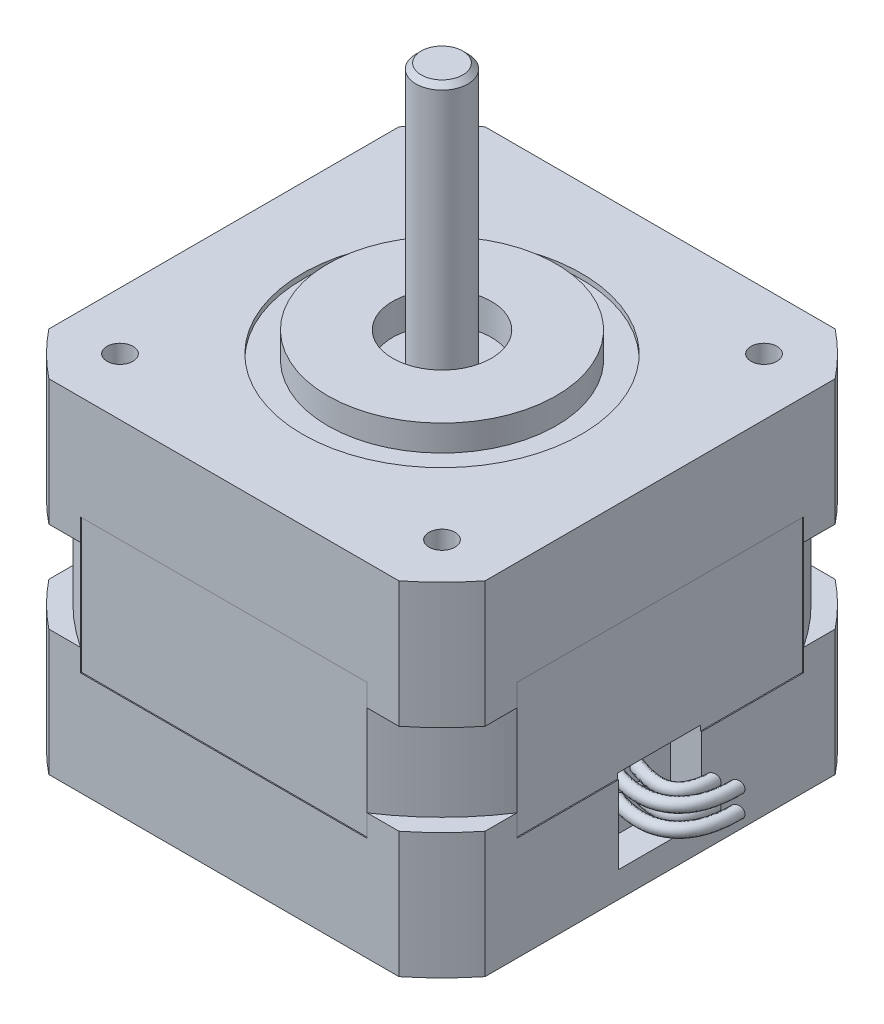
from build123d import *

# Parameters (mm, degrees)
BOSS_EXTRUDE2_DEPTH       = 33
SKETCH3_W                 = 5
SKETCH3_H                 = 8.75
SKETCH4_R                 = 13.425
CUT_EXTRUDE1_DEPTH        = 0.5
SKETCH5_R                 = 11
BOSS_EXTRUDE3_DEPTH       = 2.5
SKETCH6_R                 = 4.75
CUT_EXTRUDE2_DEPTH        = 3
SKETCH7_R                 = 2.5
BOSS_EXTRUDE4_DEPTH       = 25.25
CHAMFER1_SIZE             = 0.5
SKETCH8_R                 = 4.5
CUT_EXTRUDE3_DEPTH        = 3
M3X0_5_TAPPED_HOLE1_D     = 2.5
M3X0_5_TAPPED_HOLE1_DEPTH = 4.5
M3X0_5_TAPPED_HOLE1_TIP   = 0.751075774
SKETCH12_W                = 8
SKETCH12_H                = 8
CUT_EXTRUDE4_DEPTH        = 3
SKETCH13_R                = 0.6
SKETCH15_W                = 27.587361236
SKETCH15_H                = 13
CUT_EXTRUDE5_DEPTH        = 0.1
CIRPATTERN1_COUNT         = 4


with BuildPart() as part:
    # Sketch1 → Boss-Extrude2 (new body)
    with BuildSketch(Plane(origin=(0, 0, 0), x_dir=(1, 0, 0), z_dir=(0, 1, 0))):
        with BuildLine():
            Line((-21, 16.850982909), (-21, -16.850982909))
            ThreePointArc((-21, -16.850982909), (-19.038850083, -19.038850083), (-16.850982909, -21))
            Line((-16.850982909, -21), (16.850982909, -21))
            ThreePointArc((16.850982909, -21), (19.038850083, -19.038850083), (21, -16.850982909))
            Line((21, -16.850982909), (21, 16.850982909))
            ThreePointArc((21, 16.850982909), (19.038850083, 19.038850083), (16.850982909, 21))
            Line((16.850982909, 21), (-16.850982909, 21))
            ThreePointArc((-16.850982909, 21), (-19.038850083, 19.038850083), (-21, 16.850982909))
        make_face()
    extrude(amount=BOSS_EXTRUDE2_DEPTH)

    # Sketch3 → Cut-Revolve1 (revolve, cut)
    with BuildSketch(Plane.XY):
        with Locations((-27.625, 16.5)):
            Rectangle(SKETCH3_W, SKETCH3_H)
    revolve(axis=Axis((0, -2.013056064, 0), (0, 1, 0)), mode=Mode.SUBTRACT)

    # Sketch4 → Cut-Extrude1 (cut)
    with BuildSketch(Plane(origin=(0, 33, 0), x_dir=(1, 0, 0), z_dir=(0, 1, 0))):
        Circle(SKETCH4_R)
    extrude(amount=-CUT_EXTRUDE1_DEPTH, mode=Mode.SUBTRACT)

    # Sketch5 → Boss-Extrude3 (add)
    with BuildSketch(Plane(origin=(0, 32.5, 0), x_dir=(1, 0, 0), z_dir=(0, 1, 0))):
        Circle(SKETCH5_R)
    extrude(amount=BOSS_EXTRUDE3_DEPTH)

    # Sketch6 → Cut-Extrude2 (cut)
    with BuildSketch(Plane(origin=(0, 35, 0), x_dir=(1, 0, 0), z_dir=(0, 1, 0))):
        Circle(SKETCH6_R)
    extrude(amount=-CUT_EXTRUDE2_DEPTH, mode=Mode.SUBTRACT)

    # Sketch7 → Boss-Extrude4 (add)
    with BuildSketch(Plane(origin=(0, 32, 0), x_dir=(1, 0, 0), z_dir=(0, 1, 0))):
        Circle(SKETCH7_R)
    extrude(amount=BOSS_EXTRUDE4_DEPTH)

    # Chamfer1
    chamfer1_edges = [part.edges().sort_by_distance(p)[0] for p in [
        (-2.5, 57.25, 0),
    ]]
    chamfer(chamfer1_edges, length=CHAMFER1_SIZE)

    # Sketch8 → Cut-Extrude3 (cut)
    with BuildSketch(Plane.XZ):
        Circle(SKETCH8_R)
    extrude(amount=-CUT_EXTRUDE3_DEPTH, mode=Mode.SUBTRACT)

    # M3x0.5 Tapped Hole1
    with Locations(Plane(origin=(0, 33, 0), x_dir=(1, 0, 0), z_dir=(0, 1, 0))):
        with Locations((-15.5, -15.5), (-15.5, 15.5), (15.5, 15.5), (15.5, -15.5)):
            Hole(M3X0_5_TAPPED_HOLE1_D / 2, depth=M3X0_5_TAPPED_HOLE1_DEPTH)
            with Locations((0, 0, -(M3X0_5_TAPPED_HOLE1_DEPTH + M3X0_5_TAPPED_HOLE1_TIP / 2))):  # 118° drill point
                Cone(0, M3X0_5_TAPPED_HOLE1_D / 2, M3X0_5_TAPPED_HOLE1_TIP, mode=Mode.SUBTRACT)

    # Sketch12 → Cut-Extrude4 (cut)
    with BuildSketch(Plane(origin=(21, 0, 0), x_dir=(0, 0, -1), z_dir=(1, 0, 0))):
        with Locations((0, 6.5)):
            Rectangle(SKETCH12_W, SKETCH12_H)
    extrude(amount=-CUT_EXTRUDE4_DEPTH, mode=Mode.SUBTRACT)

    # Sweep2: sweep along a path in Sketch14
    with BuildLine() as sweep2_path:  # in the path sketch's own coordinates; laid on its plane below (add() does not lay a ready-made edge on the line's plane)
        add(Edge.make_bspline(
            [(17.676713236, 0), (23.6460823, -2.366766531), (23.798444163, 3.357568307)],
            knots=[0, 0, 0, 1, 1, 1], degree=2))
    # Sketch13 → Sweep2 (sweep)
    with BuildSketch(Plane(origin=(18, 0, 0), x_dir=(0, 0, -1), z_dir=(1, 0, 0))):
        with Locations((-1.112460133, 7.415030797)):
            Circle(SKETCH13_R)
        with Locations((0.707044587, 7.415030797)):
            Circle(SKETCH13_R)
        with Locations((-1.112460133, 5.332176709)):
            Circle(SKETCH13_R)
        with Locations((0.707044587, 5.332176709)):
            Circle(SKETCH13_R)
    sweep(path=Plane(origin=(0, 0, 0), x_dir=(1, 0, 0), z_dir=(0, 1, 0)) * sweep2_path.line)

    # Sketch15 → Cut-Extrude5 (cut)
    with BuildSketch(Plane(origin=(0, 0, -21), x_dir=(-1, 0, 0), z_dir=(0, 0, -1))):
        with Locations((0, 16.5)):
            Rectangle(SKETCH15_W, SKETCH15_H)
    cut_extrude5 = extrude(amount=-CUT_EXTRUDE5_DEPTH, mode=Mode.SUBTRACT)

    # CirPattern1: Cut-Extrude5 ×4 about axis
    cirpattern1_axis = Axis((0, 0, 0), (0, 1, 0))
    for i in range(1, CIRPATTERN1_COUNT):
        add(cut_extrude5.rotate(cirpattern1_axis, i * 360 / CIRPATTERN1_COUNT), mode=Mode.SUBTRACT)


solid = part.part
